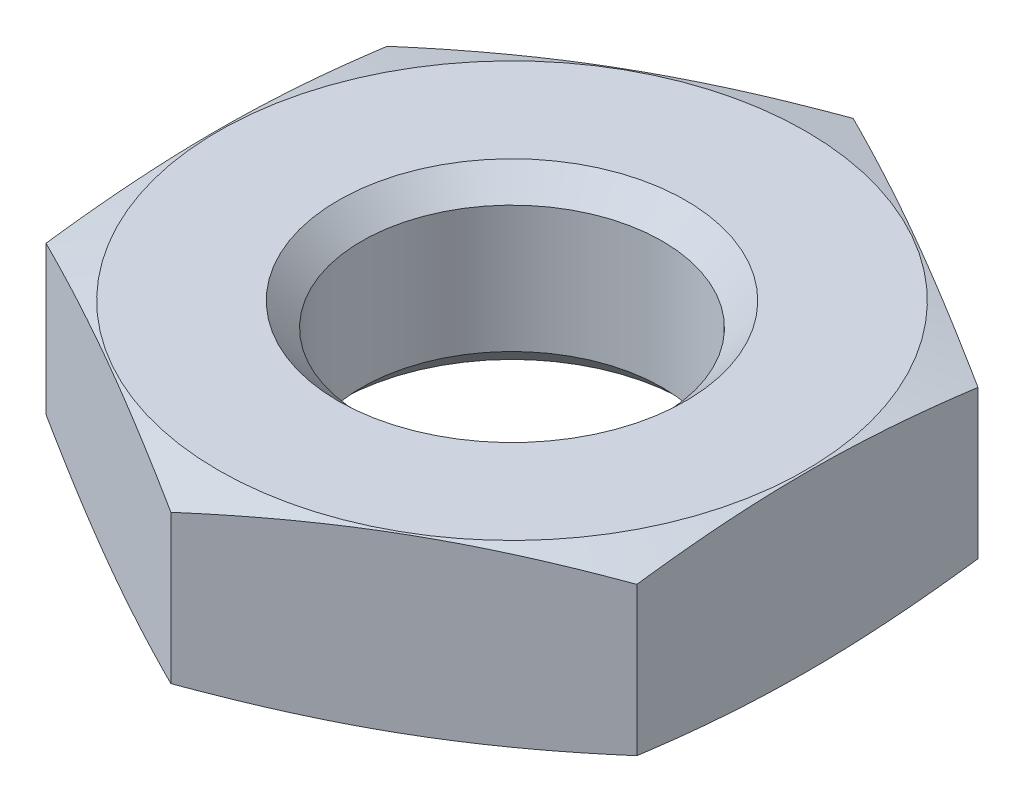
from build123d import *

# Parameters (mm, degrees)
CUT_EXTRUDE1_DEPTH      = 6
CUT_EXTRUDE1_DEPTH_BACK = 6
SKETCH2_W               = 68
SKETCH2_H               = 68


with BuildPart() as part:
    # Sketch1 → Revolve1 (revolve)
    with BuildSketch(Plane.XY):
        Polygon((0, 0), (8.45, 0), (17.780127019, -2.5), (8.45, -5), (0, -5), align=None)
    revolve(axis=Axis((0, -5, 0), (0, 1, 0)))

    # Sketch2 → Cut-Extrude1 (cut, two sides: drawn at the far end of the back side and taken through both)
    with BuildSketch(Plane(origin=(0, 0, 0), x_dir=(1, 0, 0), z_dir=(0, 1, 0)).offset(-CUT_EXTRUDE1_DEPTH_BACK)):
        Rectangle(SKETCH2_W, SKETCH2_H)
        Polygon((-8.5, -4.907477288), (0, -9.814954576), (8.5, -4.907477288), (8.5, 4.907477288), (0, 9.814954576), (-8.5, 4.907477288), align=None, mode=Mode.SUBTRACT)
    extrude(amount=CUT_EXTRUDE1_DEPTH + CUT_EXTRUDE1_DEPTH_BACK, mode=Mode.SUBTRACT)

    # Sketch3 → Cut-Revolve1 (revolve, cut)
    with BuildSketch(Plane.XY):
        Polygon((0, 0), (5, 0), (4.3235, -0.6765), (4.3235, -4.3235), (5, -5), (0, -5), align=None)
    revolve(axis=Axis((0, -5, 0), (0, 1, 0)), mode=Mode.SUBTRACT)


solid = part.part
